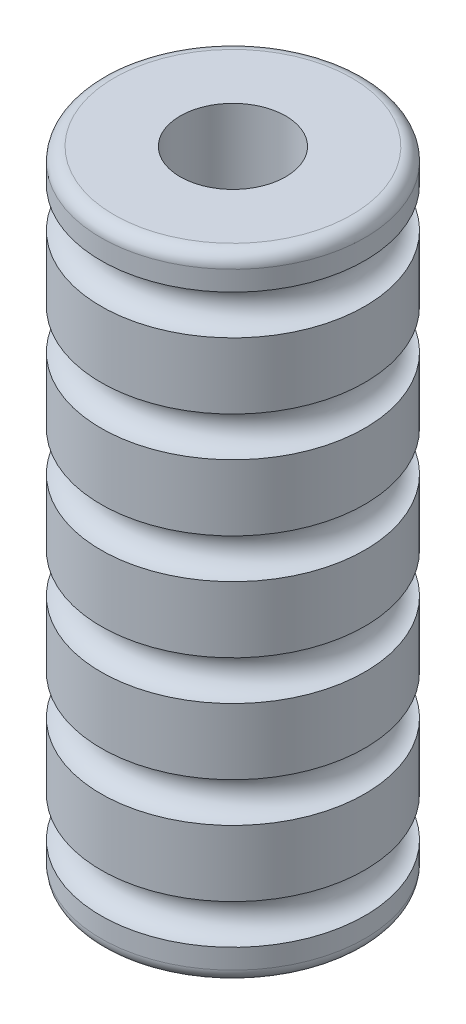
from build123d import *

# Parameters (mm, degrees)
CUT_EXTRUDE1_REACH = 154.4
SKETCH2_R          = 12.7


with BuildPart() as part:
    # Sketch1 → Revolve1 (revolve)
    with BuildSketch(Plane(origin=(0, 0, 0), x_dir=(0, 0, -1), z_dir=(1, 0, 0))):
        with BuildLine():
            Line((31.75, 144.4625), (31.75, 149.225))
            ThreePointArc((31.75, 149.225), (30.82006403, 151.47006403), (28.575, 152.4))
            Line((28.575, 152.4), (0, 152.4))
            Line((0, 152.4), (0, 0))
            Line((0, 0), (28.575, 0))
            ThreePointArc((28.575, 0), (30.82006403, 0.92993597), (31.75, 3.175))
            Line((31.75, 3.175), (31.75, 7.9375))
            ThreePointArc((31.75, 7.9375), (26.9875, 12.7), (31.75, 17.4625))
            Line((31.75, 17.4625), (31.75, 33.3375))
            ThreePointArc((31.75, 33.3375), (26.9875, 38.1), (31.75, 42.8625))
            Line((31.75, 42.8625), (31.75, 58.7375))
            ThreePointArc((31.75, 58.7375), (26.9875, 63.5), (31.75, 68.2625))
            Line((31.75, 68.2625), (31.75, 84.1375))
            ThreePointArc((31.75, 84.1375), (26.9875, 88.9), (31.75, 93.6625))
            Line((31.75, 93.6625), (31.75, 109.5375))
            ThreePointArc((31.75, 109.5375), (26.9875, 114.3), (31.75, 119.0625))
            Line((31.75, 119.0625), (31.75, 134.9375))
            ThreePointArc((31.75, 134.9375), (26.9875, 139.7), (31.75, 144.4625))
        make_face()
    revolve(axis=Axis((0, 0, 0), (0, 1, 0)))

    # Sketch2 → Cut-Extrude1 (cut, up to next)
    with BuildSketch(Plane.XZ, mode=Mode.PRIVATE) as cut_extrude1_sk1:
        Circle(SKETCH2_R)
    cut_extrude1_tool1 = extrude(cut_extrude1_sk1.sketch, amount=-CUT_EXTRUDE1_REACH, mode=Mode.PRIVATE) & part.part
    add(cut_extrude1_tool1.solids().sort_by_distance((0, 0, 0))[0], mode=Mode.SUBTRACT)


solid = part.part
